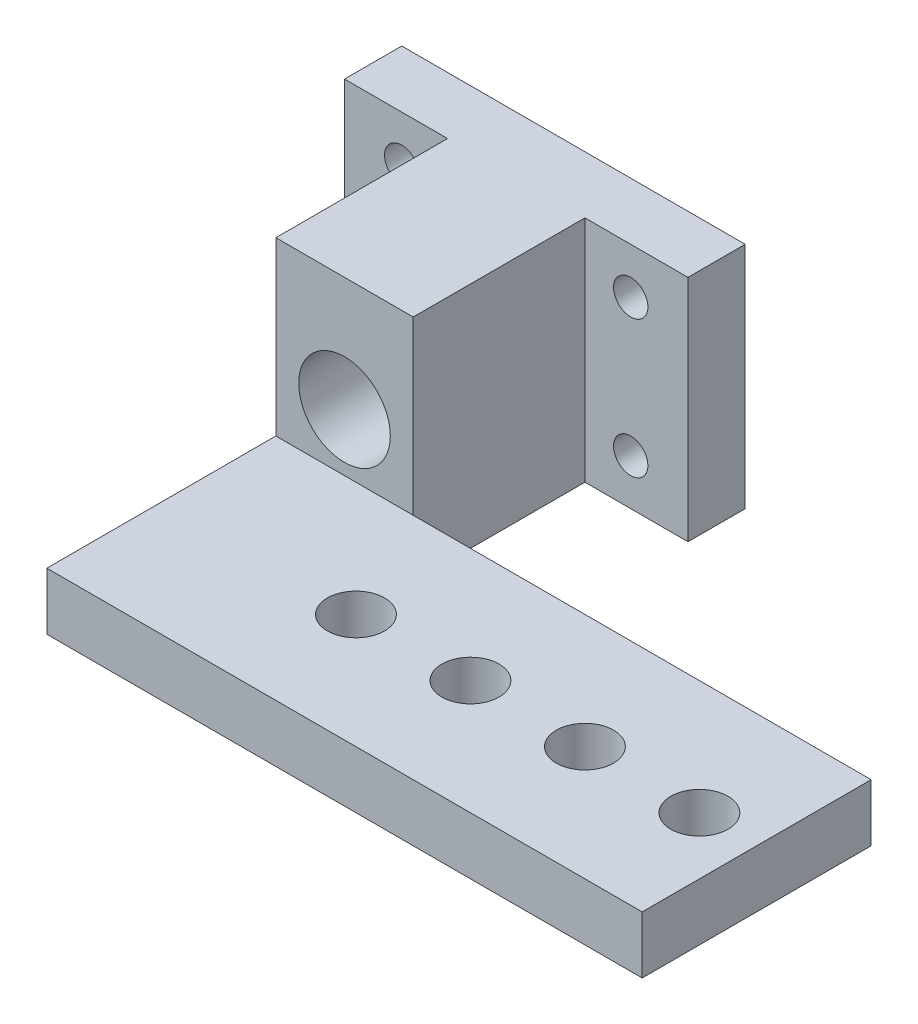
from build123d import *

# Parameters (mm, degrees)
SKETCH_1_W          = 30
SKETCH_1_H          = 20
SKETCH_1_R          = 1.5
SKETCH_1_R_2        = 4
EXTRUDE_1_DEPTH     = 20
SKETCH_2_W          = 9
SKETCH_2_H          = 20
CUT_EXTRUDE_1_DEPTH = 15
SKETCH_3_W          = 12
SKETCH_3_H          = 5
EXTRUDE_2_DEPTH     = 20
SKETCH_4_W          = 20
SKETCH_4_H          = 5
EXTRUDE_3_DEPTH     = 40
SKETCH_5_R          = 2.5
CUT_EXTRUDE_2_DEPTH = 20


with BuildPart() as part:
    # 草图1 → 凸台-拉伸1 (new body)
    with BuildSketch(Plane.XY):
        with Locations((15, -10)):
            Rectangle(SKETCH_1_W, SKETCH_1_H)
        with Locations((5, -4)):
            Circle(SKETCH_1_R, mode=Mode.SUBTRACT)
        with Locations((25, -4)):
            Circle(SKETCH_1_R, mode=Mode.SUBTRACT)
        with Locations((25, -16)):
            Circle(SKETCH_1_R, mode=Mode.SUBTRACT)
        with Locations((5, -16)):
            Circle(SKETCH_1_R, mode=Mode.SUBTRACT)
        with Locations((15, -10)):
            Circle(SKETCH_1_R_2, mode=Mode.SUBTRACT)
    extrude(amount=EXTRUDE_1_DEPTH)

    # 草图2 → 切除-拉伸1 (cut)
    with BuildSketch(Plane.XY.offset(20)):
        with Locations((4.5, -10)):
            Rectangle(SKETCH_2_W, SKETCH_2_H)
        with Locations((25.5, -10)):
            Rectangle(SKETCH_2_W, SKETCH_2_H)
    extrude(amount=-CUT_EXTRUDE_1_DEPTH, mode=Mode.SUBTRACT)

    # 草图3 → 凸台-拉伸2 (add)
    with BuildSketch(Plane.XY.offset(20)):
        with Locations((15, -17.5)):
            Rectangle(SKETCH_3_W, SKETCH_3_H)
    extrude(amount=EXTRUDE_2_DEPTH)

    # 草图4 → 凸台-拉伸3 (add)
    with BuildSketch(Plane(origin=(21, 0, 0), x_dir=(0, 0, -1), z_dir=(1, 0, 0))):
        with Locations((-30, -17.5)):
            Rectangle(SKETCH_4_W, SKETCH_4_H)
    extrude(amount=EXTRUDE_3_DEPTH)

    # 草图5 → 切除-拉伸2 (cut)
    with BuildSketch(Plane(origin=(0, -15, 0), x_dir=(1, 0, 0), z_dir=(0, 1, 0))):
        with Locations((26, -30)):
            Circle(SKETCH_5_R)
        with Locations((36, -30)):
            Circle(SKETCH_5_R)
        with Locations((46, -30)):
            Circle(SKETCH_5_R)
        with Locations((56, -30)):
            Circle(SKETCH_5_R)
    extrude(amount=-CUT_EXTRUDE_2_DEPTH, mode=Mode.SUBTRACT)


solid = part.part
